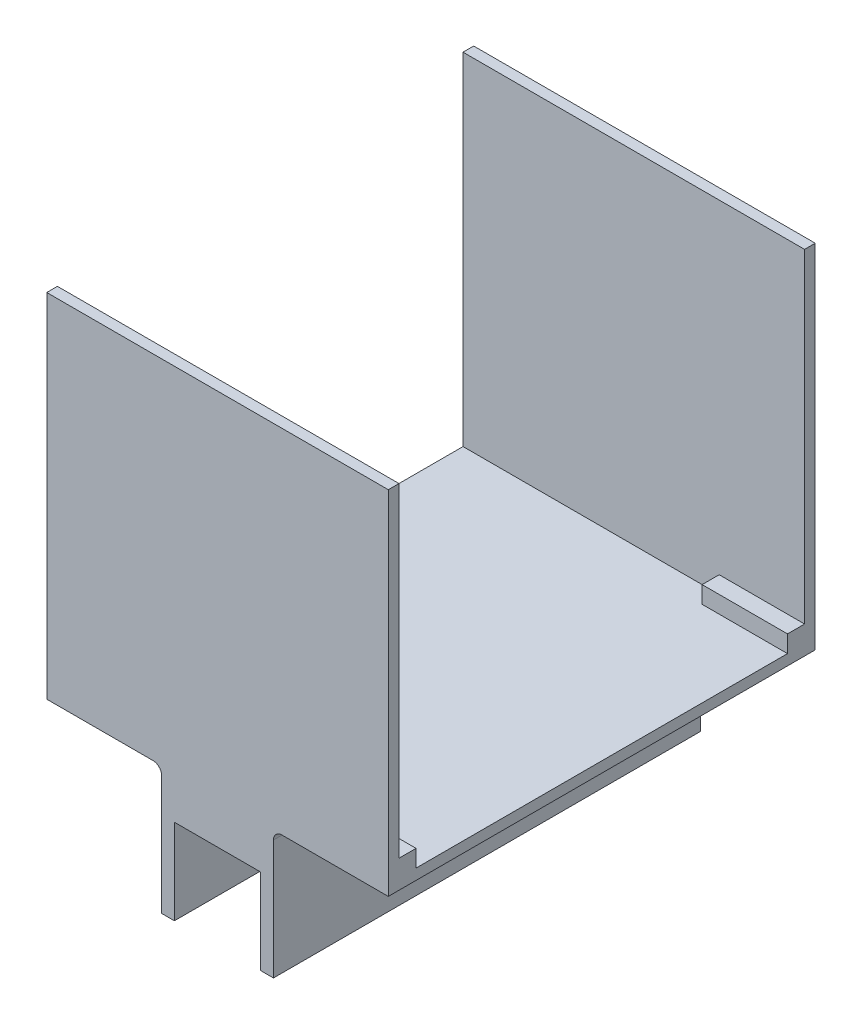
from build123d import *

# Parameters (mm, degrees)
BOSS_EXTRUDE1_DEPTH = 127
SKETCH5_W           = 101.6
SKETCH5_H           = 127
BOSS_EXTRUDE3_DEPTH = 3.175
FILLET1_R           = 2.54
SKETCH6_W           = 101.6
SKETCH6_H           = 3.175
BOSS_EXTRUDE4_DEPTH = 101.6
BOSS_EXTRUDE6_DEPTH = 25.4
BOSS_EXTRUDE7_DEPTH = 0.254
BOSS_EXTRUDE8_DEPTH = 25.4
BOSS_EXTRUDE9_DEPTH = 0.254


with BuildPart() as part:
    # Sketch2 → Boss-Extrude1 (new body)
    with BuildSketch(Plane.XY):
        Polygon((-12.827, -12.7), (-16.637, -12.7), (-16.637, 25.4), (16.637, 25.4), (16.637, -12.7), (12.827, -12.7), (12.827, 12.7), (-12.827, 12.7), align=None)
    extrude(amount=BOSS_EXTRUDE1_DEPTH)

    # Sketch5 → Boss-Extrude3 (add)
    with BuildSketch(Plane(origin=(0, 25.4, 0), x_dir=(1, 0, 0), z_dir=(0, 1, 0))):
        with Locations((0, -63.5)):
            Rectangle(SKETCH5_W, SKETCH5_H)
    extrude(amount=BOSS_EXTRUDE3_DEPTH)

    # Fillet1
    fillet1_edges = [part.edges().sort_by_distance(p)[0] for p in [
        (-16.637, 25.4, 63.5),
        (16.637, 25.4, 63.5),
    ]]
    fillet(fillet1_edges, radius=FILLET1_R)

    # Sketch6 → Boss-Extrude4 (add)
    with BuildSketch(Plane(origin=(0, 28.575, 0), x_dir=(1, 0, 0), z_dir=(0, 1, 0))):
        with Locations((0, -125.4125)):
            Rectangle(SKETCH6_W, SKETCH6_H)
        with Locations((0, -1.5875)):
            Rectangle(SKETCH6_W, SKETCH6_H)
    extrude(amount=BOSS_EXTRUDE4_DEPTH)

    # Sketch9 → Boss-Extrude6 (add)
    with BuildSketch(Plane(origin=(50.8, 0, 0), x_dir=(0, 0, -1), z_dir=(1, 0, 0))):
        with BuildLine():
            Line((-123.825, 33.655), (-123.825, 29.9085))
            ThreePointArc((-123.825, 29.9085), (-121.548573107, 30.851426893), (-122.4915, 28.575))
            Line((-122.4915, 28.575), (-118.745, 28.575))
            Line((-118.745, 28.575), (-118.745, 33.655))
            Line((-118.745, 33.655), (-123.825, 33.655))
        make_face()
    extrude(amount=-BOSS_EXTRUDE6_DEPTH)

    # Sketch10 → Boss-Extrude7 (add)
    with BuildSketch(Plane(origin=(50.8, 0, 0), x_dir=(0, 0, -1), z_dir=(1, 0, 0))):
        with BuildLine():
            Line((-123.825, 29.9085), (-123.825, 28.575))
            Line((-123.825, 28.575), (-122.4915, 28.575))
            ThreePointArc((-122.4915, 28.575), (-121.548573107, 30.851426893), (-123.825, 29.9085))
        make_face()
    extrude(amount=-BOSS_EXTRUDE7_DEPTH)

    # Sketch17 → Boss-Extrude8 (add)
    with BuildSketch(Plane(origin=(50.8, 0, 0), x_dir=(0, 0, -1), z_dir=(1, 0, 0))):
        with BuildLine():
            Line((-8.255, 28.575), (-4.5085, 28.575))
            ThreePointArc((-4.5085, 28.575), (-5.451426893, 30.851426893), (-3.175, 29.9085))
            Line((-3.175, 29.9085), (-3.175, 33.655))
            Line((-3.175, 33.655), (-8.255, 33.655))
            Line((-8.255, 33.655), (-8.255, 28.575))
        make_face()
    extrude(amount=-BOSS_EXTRUDE8_DEPTH)

    # Sketch18 → Boss-Extrude9 (add)
    with BuildSketch(Plane(origin=(50.8, 0, 0), x_dir=(0, 0, -1), z_dir=(1, 0, 0))):
        with BuildLine():
            Line((-3.175, 29.9085), (-3.175, 28.575))
            Line((-3.175, 28.575), (-4.5085, 28.575))
            ThreePointArc((-4.5085, 28.575), (-5.451426893, 30.851426893), (-3.175, 29.9085))
        make_face()
    extrude(amount=-BOSS_EXTRUDE9_DEPTH)


solid = part.part
